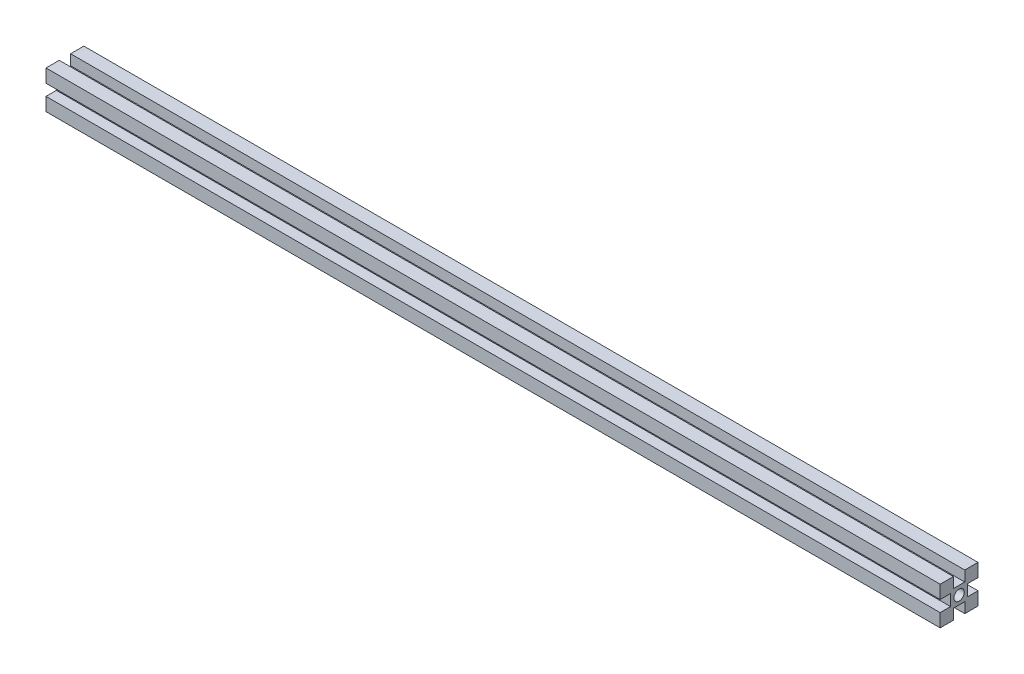
from build123d import *

# Parameters (mm, degrees)
ESQUISSE1_R        = 2.75
BOSS_EXTRU_1_DEPTH = 472.5


with BuildPart() as part:
    # Esquisse1 → Boss.-Extru.1 (new body)
    with BuildSketch(Plane(origin=(0, 0, 0), x_dir=(0, -1, 0), z_dir=(-1, 0, 0))):
        Polygon((-3, -10), (-3, -4.5), (3, -4.5), (3, -10), (10, -10), (10, -3), (4.5, -3), (4.5, 3), (10, 3), (10, 10), (3, 10), (3, 4.5), (-3, 4.5), (-3, 10), (-10, 10), (-10, 3), (-4.5, 3), (-4.5, -3), (-10, -3), (-10, -10), align=None)
        Circle(ESQUISSE1_R, mode=Mode.SUBTRACT)
    extrude(amount=-BOSS_EXTRU_1_DEPTH)


solid = part.part
